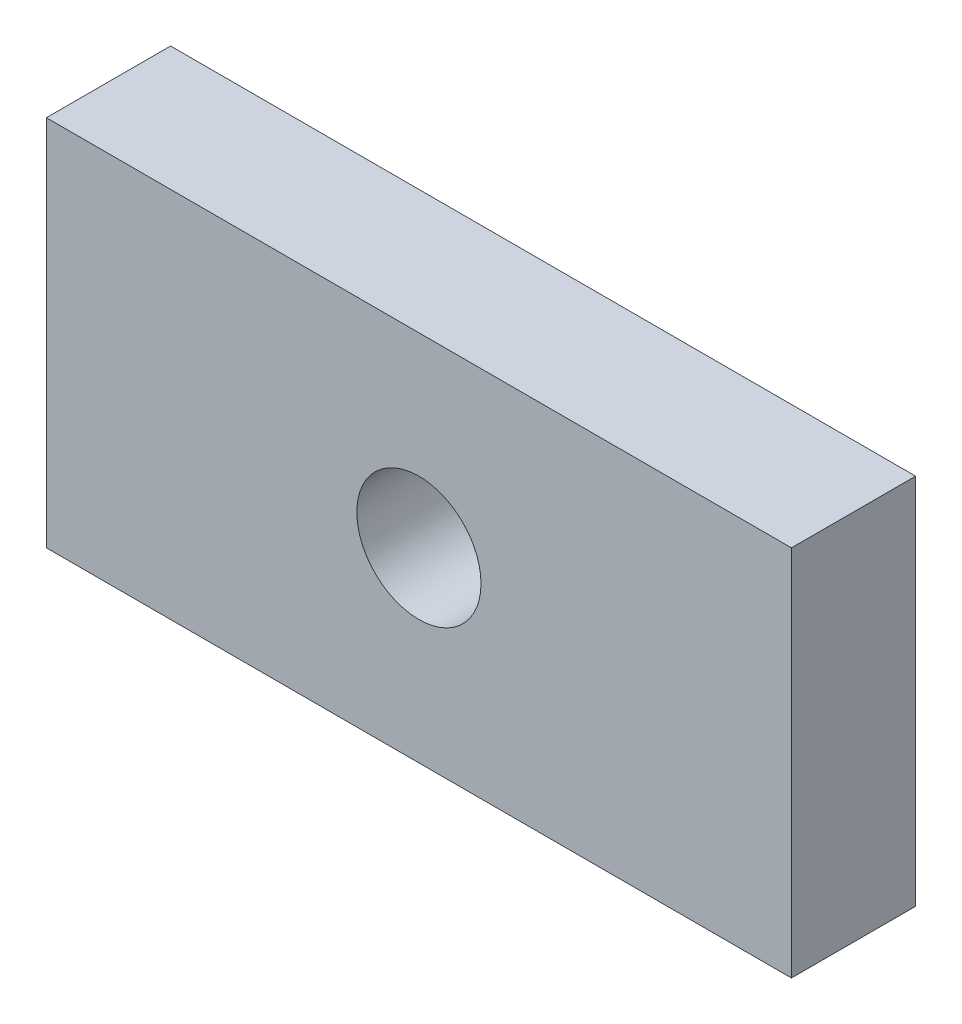
from build123d import *

# Parameters (mm, degrees)
SKETCH1_W           = 76.2
SKETCH1_H           = 38.1
SKETCH1_R           = 6.35
BOSS_EXTRUDE1_DEPTH = 12.7


with BuildPart() as part:
    # Sketch1 → Boss-Extrude1 (new body)
    with BuildSketch(Plane.XY):
        with Locations((38.1, 19.05)):
            Rectangle(SKETCH1_W, SKETCH1_H)
        with Locations((38.1, 19.05)):
            Circle(SKETCH1_R, mode=Mode.SUBTRACT)
    extrude(amount=BOSS_EXTRUDE1_DEPTH)


solid = part.part
